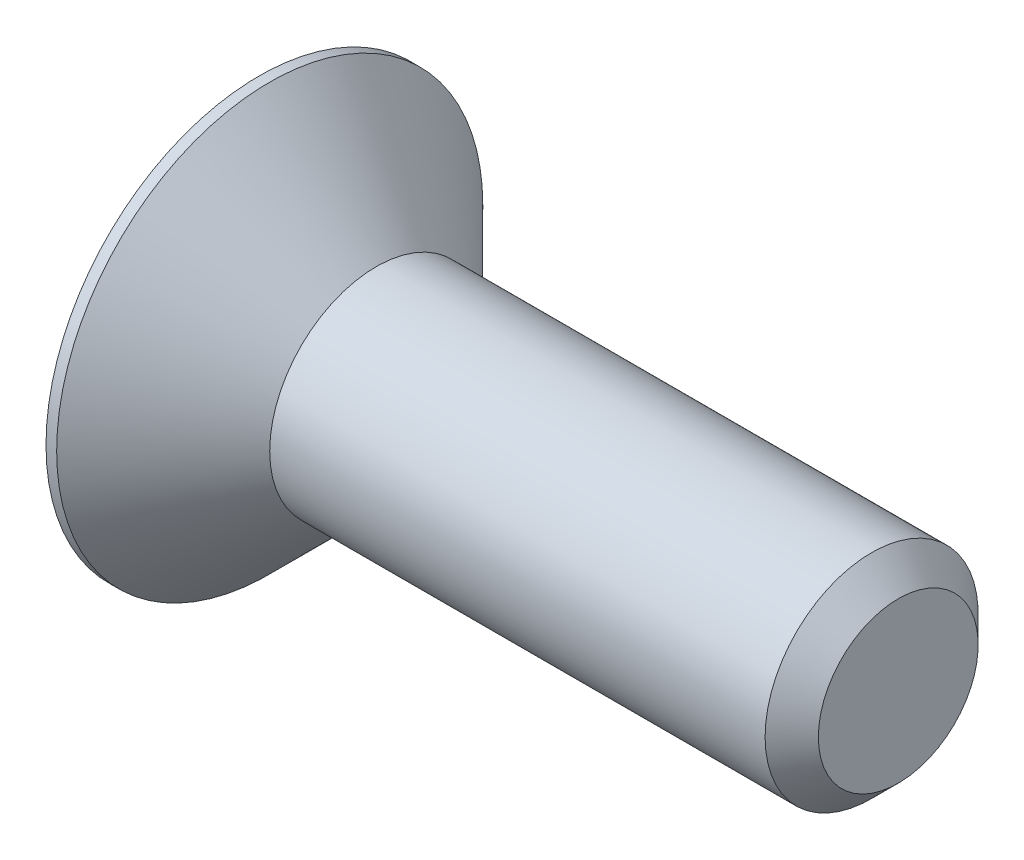
from build123d import *

# Parameters (mm, degrees)
CUT_EXTRUDE1_DEPTH = 0.8


with BuildPart() as part:
    # Sketch2 → Revolve1 (revolve)
    with BuildSketch(Plane.XY):
        Polygon((0, 0), (0, 2), (0.1, 2), (1.1, 1), (5.75, 1), (6, 0.75), (6, 0), align=None)
    revolve(axis=Axis((-2.281841559, 0, 0), (1, 0, 0)))

    # Sketch3 → Cut-Extrude1 (cut)
    with BuildSketch(Plane.ZY):
        Polygon((0.433012702, -0.75), (0.866025404, 0), (0.433012702, 0.75), (-0.433012702, 0.75), (-0.866025404, 0), (-0.433012702, -0.75), align=None)
    extrude(amount=-CUT_EXTRUDE1_DEPTH, mode=Mode.SUBTRACT)


solid = part.part
